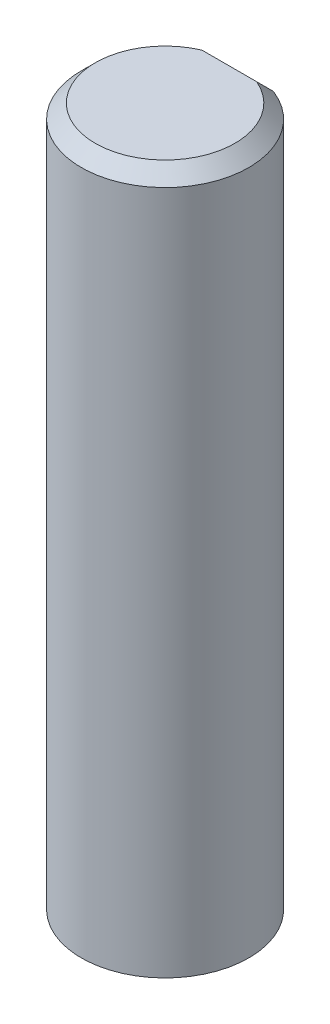
from build123d import *

# Parameters (mm, degrees)
BOSS_EXTRUDE1_DEPTH   = 25
CHAMFER1_SIZE2        = 0.500023177
CHAMFER1_SIZE         = 0.500027299
CHAMFER1_EDGE_2_SIZE2 = 0.500023177
CHAMFER1_EDGE_2_SIZE  = 0.500027299


with BuildPart() as part:
    # Sketch1 → Boss-Extrude1 (new body)
    with BuildSketch(Plane(origin=(0, 25, 0), x_dir=(1, 0, 0), z_dir=(0, 1, 0))):
        with BuildLine():
            Line((1.077032961, 2.8), (-1.077032961, 2.8))
            ThreePointArc((-1.077032961, 2.8), (0, -3), (1.077032961, 2.8))
        make_face()
    extrude(amount=-BOSS_EXTRUDE1_DEPTH)

    # Chamfer1
    chamfer1_edges = [part.edges().sort_by_distance(p)[0] for p in [
        (0, 25, -2.8),
    ]]
    chamfer(chamfer1_edges, length=CHAMFER1_SIZE, length2=CHAMFER1_SIZE2)

    # Chamfer1 edge 2
    chamfer1_edge_2_edges = [part.edges().sort_by_distance(p)[0] for p in [
        (0, 25, 3),
    ]]
    chamfer(chamfer1_edge_2_edges, length=CHAMFER1_EDGE_2_SIZE, length2=CHAMFER1_EDGE_2_SIZE2)


solid = part.part
